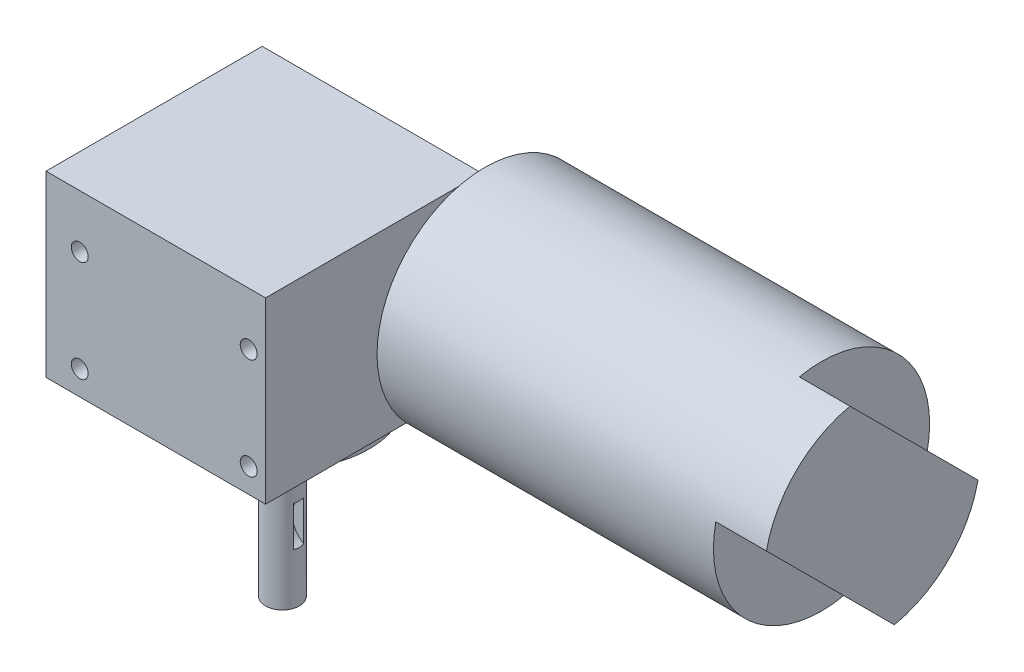
from build123d import *

# Parameters (mm, degrees)
SKETCH1_R           = 32
MOTORBODY_DEPTH     = 99.6
SKETCH2_R           = 15
MOTORAXLE_DEPTH     = 66
SKETCH3_W           = 65
SKETCH3_H           = 58.4
GEARBOX_DEPTH       = 64
SKETCH4_R           = 5
BOSS_EXTRUDE4_DEPTH = 50.6
SKETCH5_R           = 12.375
SKETCH5_R_2         = 10.375
BOSS_EXTRUDE5_DEPTH = 3.6
SKETCH6_R           = 2
CUT_EXTRUDE1_DEPTH  = 10
BOSS_EXTRUDE6_DEPTH = 15
CUT_EXTRUDE2_DEPTH  = 1.5
SKETCH10_R          = 1.95
SKETCH10_R_2        = 1.5
CUT_EXTRUDE3_DEPTH  = 9.5
SKETCH11_W          = 65
SKETCH11_H          = 64
SKETCH11_R          = 25.7
CUT_EXTRUDE4_DEPTH  = 5.5
SKETCH12_R          = 2.5
CUT_EXTRUDE5_DEPTH  = 13
SKETCH13_R          = 2.5
CUT_EXTRUDE11_DEPTH = 12.75
SKETCH14_R          = 2.5
CUT_EXTRUDE12_DEPTH = 10


with BuildPart() as part:
    # Sketch1 → MotorBody (new body)
    with BuildSketch(Plane(origin=(0, 0, 0), x_dir=(0, 0, -1), z_dir=(1, 0, 0))):
        Circle(SKETCH1_R)
    extrude(amount=MOTORBODY_DEPTH)

    # Sketch2 → MotorAxle (add)
    with BuildSketch(Plane.ZY):
        Circle(SKETCH2_R)
    extrude(amount=MOTORAXLE_DEPTH)

    # Sketch3 → Gearbox (add)
    with BuildSketch(Plane.XY):
        with Locations((-33.5, 0.8)):
            Rectangle(SKETCH3_W, SKETCH3_H)
    extrude(amount=GEARBOX_DEPTH)

    # Sketch4 → Boss-Extrude4 (add)
    with BuildSketch(Plane.XZ.offset(28.4)):
        with Locations((-31, 29)):
            Circle(SKETCH4_R)
    extrude(amount=BOSS_EXTRUDE4_DEPTH)

    # Sketch5 → Boss-Extrude5 (add)
    with BuildSketch(Plane.XZ.offset(28.4)):
        with Locations((-31, 29)):
            Circle(SKETCH5_R)
        with Locations((-31, 29)):
            Circle(SKETCH5_R_2, mode=Mode.SUBTRACT)
    extrude(amount=BOSS_EXTRUDE5_DEPTH)

    # Sketch6 → Cut-Extrude1 (cut)
    with BuildSketch(Plane.XZ.offset(79)):
        with Locations((-31, 29)):
            Circle(SKETCH6_R)
    extrude(amount=-CUT_EXTRUDE1_DEPTH, mode=Mode.SUBTRACT)

    # Sketch7 → Boss-Extrude6 (add)
    with BuildSketch(Plane(origin=(99.6, 0, 0), x_dir=(0, 0, -1), z_dir=(1, 0, 0))):
        with BuildLine():
            Line((-31.318365081, 6.56962774), (6.56962774, -31.318365081))
            ThreePointArc((6.56962774, -31.318365081), (22.627416998, -22.627416998), (31.318365081, -6.56962774))
            Line((31.318365081, -6.56962774), (-6.56962774, 31.318365081))
            ThreePointArc((-6.56962774, 31.318365081), (-22.627416998, 22.627416998), (-31.318365081, 6.56962774))
        make_face()
    extrude(amount=BOSS_EXTRUDE6_DEPTH)

    # Sketch9 → Cut-Extrude2 (cut, symmetric)
    with BuildSketch(Plane.XY.offset(29)):
        with BuildLine():
            Line((-26, -64), (-26, -52))
            ThreePointArc((-26, -52), (-29.6, -58), (-26, -64))
        make_face()
    extrude(amount=CUT_EXTRUDE2_DEPTH, both=True, mode=Mode.SUBTRACT)

    # Sketch10 → Cut-Extrude3 (cut)
    with BuildSketch(Plane.XZ.offset(28.4)):
        with Locations((-45.142135624, 43.142135624)):
            Circle(SKETCH10_R)
        with Locations((-16.857864376, 43.142135624)):
            Circle(SKETCH10_R)
        with Locations((-16.857864376, 14.857864376)):
            Circle(SKETCH10_R)
        with Locations((-45.142135624, 14.857864376)):
            Circle(SKETCH10_R)
        with Locations((-31, 49)):
            Circle(SKETCH10_R_2)
        with Locations((-11, 29)):
            Circle(SKETCH10_R_2)
        with Locations((-51, 29)):
            Circle(SKETCH10_R_2)
        with Locations((-31, 9)):
            Circle(SKETCH10_R_2)
    extrude(amount=-CUT_EXTRUDE3_DEPTH, mode=Mode.SUBTRACT)

    # Sketch11 → Cut-Extrude4 (cut)
    with BuildSketch(Plane.XZ.offset(28.4)):
        with Locations((-33.5, 32)):
            Rectangle(SKETCH11_W, SKETCH11_H)
        with Locations((-31, 29)):
            Circle(SKETCH11_R, mode=Mode.SUBTRACT)
    extrude(amount=-CUT_EXTRUDE4_DEPTH, mode=Mode.SUBTRACT)

    # Sketch12 → Cut-Extrude5 (cut)
    with BuildSketch(Plane.XZ.offset(22.9)):
        with Locations((-56, 49)):
            Circle(SKETCH12_R)
        with Locations((-6, 49)):
            Circle(SKETCH12_R)
        with Locations((-6, 9)):
            Circle(SKETCH12_R)
        with Locations((-56, 9)):
            Circle(SKETCH12_R)
    extrude(amount=-CUT_EXTRUDE5_DEPTH, mode=Mode.SUBTRACT)

    # Sketch13 → Cut-Extrude11 (cut)
    with BuildSketch(Plane.XY.offset(64)):
        with Locations((-56, 14.3)):
            Circle(SKETCH13_R)
        with Locations((-6, 14.3)):
            Circle(SKETCH13_R)
        with Locations((-56, -15.7)):
            Circle(SKETCH13_R)
        with Locations((-6, -15.7)):
            Circle(SKETCH13_R)
    extrude(amount=-CUT_EXTRUDE11_DEPTH, mode=Mode.SUBTRACT)

    # Sketch14 → Cut-Extrude12 (cut)
    with BuildSketch(Plane.ZY.offset(66)):
        with Locations((4.091432188, 14.3)):
            Circle(SKETCH14_R)
        with Locations((54.091432188, 14.3)):
            Circle(SKETCH14_R)
        with Locations((4.091432188, -15.7)):
            Circle(SKETCH14_R)
        with Locations((54.091432188, -15.7)):
            Circle(SKETCH14_R)
    extrude(amount=-CUT_EXTRUDE12_DEPTH, mode=Mode.SUBTRACT)


solid = part.part
